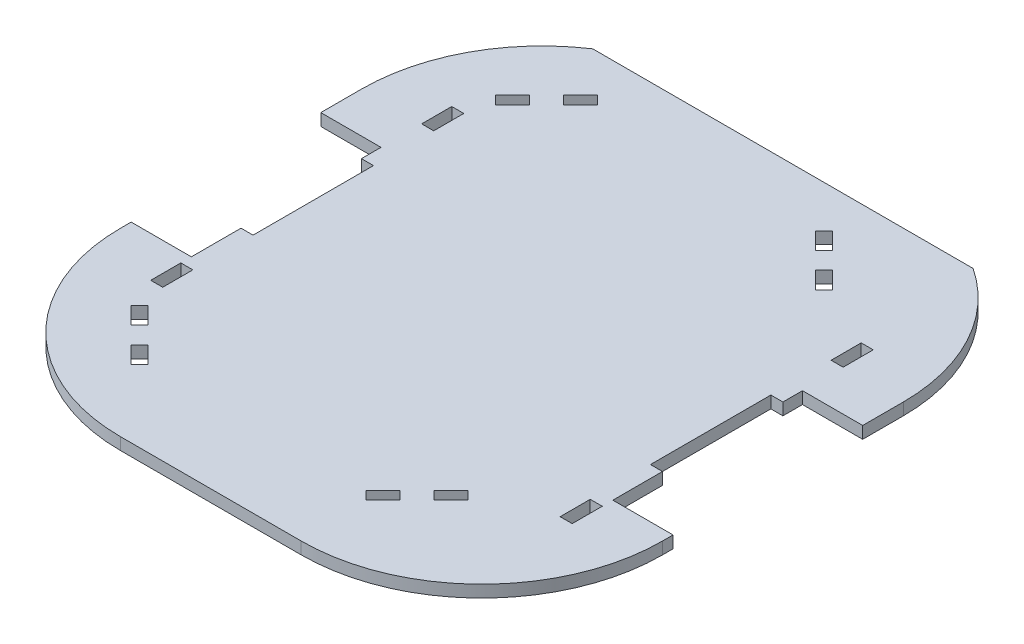
from build123d import *

# Parameters (mm, degrees)
SKETCH1_W            = 228.6
SKETCH1_H            = 241.3
BOSS_EXTRUDE1_DEPTH  = 5.08
CUT_EXTRUDE1_REACH   = 334.43
SKETCH2_W            = 25.4
SKETCH2_H            = 80
CUT_EXTRUDE2_REACH   = 334.43
SKETCH3_W            = 5.08
SKETCH3_H            = 12.7
SKETCH3_H_2          = 50.8
CUT_EXTRUDE3_REACH   = 334.43
CUT_EXTRUDE4_REACH   = 334.43
MIRROR4_COPY_1_REACH = 334.43
MIRROR4_COPY_2_REACH = 334.43


with BuildPart() as part:
    # Sketch1 → Boss-Extrude1 (new body)
    with BuildSketch(Plane(origin=(0, 0, 0), x_dir=(1, 0, 0), z_dir=(0, 1, 0))):
        with Locations((114.3, 120.65)):
            Rectangle(SKETCH1_W, SKETCH1_H)
    extrude(amount=BOSS_EXTRUDE1_DEPTH)

    # Sketch2 → Cut-Extrude1 (cut, up to next)
    with BuildSketch(Plane(origin=(0, 5.08, 0), x_dir=(1, 0, 0), z_dir=(0, 1, 0)), mode=Mode.PRIVATE) as cut_extrude1_sk1:
        with Locations((12.7, 120.65)):
            Rectangle(SKETCH2_W, SKETCH2_H)
    cut_extrude1_tool1 = extrude(cut_extrude1_sk1.sketch, amount=-CUT_EXTRUDE1_REACH, mode=Mode.PRIVATE) & part.part
    cut_extrude1 = cut_extrude1_tool1.solids().sort_by_distance((12.7, 5.08, -120.65))[0]
    add(cut_extrude1, mode=Mode.SUBTRACT)

    # Mirror1: Cut-Extrude1 across plane
    add(cut_extrude1.mirror(Plane.ZY.offset(-114.3)), mode=Mode.SUBTRACT)

    # Sketch3 → Cut-Extrude2 (cut, up to next)
    with BuildSketch(Plane.XZ, mode=Mode.PRIVATE) as cut_extrude2_sk1:
        with Locations((27.94, -184.15)):
            Rectangle(SKETCH3_W, SKETCH3_H)
    cut_extrude2_tool1 = extrude(cut_extrude2_sk1.sketch, amount=-CUT_EXTRUDE2_REACH, mode=Mode.PRIVATE) & part.part
    # Sketch3 → Cut-Extrude2 (cut, up to next)
    with BuildSketch(Plane.XZ, mode=Mode.PRIVATE) as cut_extrude2_sk2:
        with Locations((27.94, -127)):
            Rectangle(SKETCH3_W, SKETCH3_H_2)
    cut_extrude2_tool2 = extrude(cut_extrude2_sk2.sketch, amount=-CUT_EXTRUDE2_REACH, mode=Mode.PRIVATE) & part.part
    # Sketch3 → Cut-Extrude2 (cut, up to next)
    with BuildSketch(Plane.XZ, mode=Mode.PRIVATE) as cut_extrude2_sk3:
        with Locations((27.94, -69.85)):
            Rectangle(SKETCH3_W, SKETCH3_H)
    cut_extrude2_tool3 = extrude(cut_extrude2_sk3.sketch, amount=-CUT_EXTRUDE2_REACH, mode=Mode.PRIVATE) & part.part
    cut_extrude2_1 = cut_extrude2_tool1.solids().sort_by_distance((27.94, 0, -184.15))[0]
    add(cut_extrude2_1, mode=Mode.SUBTRACT)
    cut_extrude2_2 = cut_extrude2_tool2.solids().sort_by_distance((27.94, 0, -127))[0]
    add(cut_extrude2_2, mode=Mode.SUBTRACT)
    cut_extrude2_3 = cut_extrude2_tool3.solids().sort_by_distance((27.94, 0, -69.85))[0]
    add(cut_extrude2_3, mode=Mode.SUBTRACT)
    cut_extrude2 = cut_extrude2_1 + cut_extrude2_2 + cut_extrude2_3  # Cut-Extrude2 as one shape, for the pattern or mirror that repeats it

    # Mirror2: Cut-Extrude2 across plane
    add(cut_extrude2.mirror(Plane.ZY.offset(-114.3)), mode=Mode.SUBTRACT)

    # Sketch4 → Cut-Extrude3 (cut, up to next)
    with BuildSketch(Plane.XZ, mode=Mode.PRIVATE) as cut_extrude3_sk1:
        Polygon((55.639202938, -221.813411753), (48.454998041, -214.629206856), (44.862895593, -218.221309304), (52.047100489, -225.405514201), align=None)
    cut_extrude3_tool1 = extrude(cut_extrude3_sk1.sketch, amount=-CUT_EXTRUDE3_REACH, mode=Mode.PRIVATE) & part.part
    # Sketch4 → Cut-Extrude3 (cut, up to next)
    with BuildSketch(Plane.XZ, mode=Mode.PRIVATE) as cut_extrude3_sk2:
        Polygon((41.270793144, -207.445001959), (34.086588247, -200.260797062), (30.494485799, -203.852899511), (37.678690696, -211.037104407), align=None)
    cut_extrude3_tool2 = extrude(cut_extrude3_sk2.sketch, amount=-CUT_EXTRUDE3_REACH, mode=Mode.PRIVATE) & part.part
    # Sketch4 → Cut-Extrude3 (cut, up to next)
    with BuildSketch(Plane.XZ, mode=Mode.PRIVATE) as cut_extrude3_sk3:
        Polygon((34.086588247, -53.739202938), (41.270793144, -46.554998041), (37.678690696, -42.962895593), (30.494485799, -50.147100489), align=None)
    cut_extrude3_tool3 = extrude(cut_extrude3_sk3.sketch, amount=-CUT_EXTRUDE3_REACH, mode=Mode.PRIVATE) & part.part
    # Sketch4 → Cut-Extrude3 (cut, up to next)
    with BuildSketch(Plane.XZ, mode=Mode.PRIVATE) as cut_extrude3_sk4:
        Polygon((48.454998041, -39.370793144), (55.639202938, -32.186588247), (52.047100489, -28.594485799), (44.862895593, -35.778690696), align=None)
    cut_extrude3_tool4 = extrude(cut_extrude3_sk4.sketch, amount=-CUT_EXTRUDE3_REACH, mode=Mode.PRIVATE) & part.part
    # Sketch4 → Cut-Extrude3 (cut, up to next)
    with BuildSketch(Plane.XZ, mode=Mode.PRIVATE) as cut_extrude3_sk5:
        Polygon((147.560797062, -32.186588247), (154.745001959, -39.370793144), (158.337104407, -35.778690696), (151.152899511, -28.594485799), align=None)
    cut_extrude3_tool5 = extrude(cut_extrude3_sk5.sketch, amount=-CUT_EXTRUDE3_REACH, mode=Mode.PRIVATE) & part.part
    # Sketch4 → Cut-Extrude3 (cut, up to next)
    with BuildSketch(Plane.XZ, mode=Mode.PRIVATE) as cut_extrude3_sk6:
        Polygon((161.929206856, -46.554998041), (169.113411753, -53.739202938), (172.705514201, -50.147100489), (165.521309304, -42.962895593), align=None)
    cut_extrude3_tool6 = extrude(cut_extrude3_sk6.sketch, amount=-CUT_EXTRUDE3_REACH, mode=Mode.PRIVATE) & part.part
    # Sketch4 → Cut-Extrude3 (cut, up to next)
    with BuildSketch(Plane.XZ, mode=Mode.PRIVATE) as cut_extrude3_sk7:
        Polygon((154.745001959, -214.629206856), (147.560797062, -221.813411753), (151.152899511, -225.405514201), (158.337104407, -218.221309304), align=None)
    cut_extrude3_tool7 = extrude(cut_extrude3_sk7.sketch, amount=-CUT_EXTRUDE3_REACH, mode=Mode.PRIVATE) & part.part
    # Sketch4 → Cut-Extrude3 (cut, up to next)
    with BuildSketch(Plane.XZ, mode=Mode.PRIVATE) as cut_extrude3_sk8:
        Polygon((169.113411753, -200.260797062), (161.929206856, -207.445001959), (165.521309304, -211.037104407), (172.705514201, -203.852899511), align=None)
    cut_extrude3_tool8 = extrude(cut_extrude3_sk8.sketch, amount=-CUT_EXTRUDE3_REACH, mode=Mode.PRIVATE) & part.part
    add(cut_extrude3_tool1.solids().sort_by_distance((50.251049, 0, -220.017361))[0], mode=Mode.SUBTRACT)
    add(cut_extrude3_tool2.solids().sort_by_distance((35.882639, 0, -205.648951))[0], mode=Mode.SUBTRACT)
    add(cut_extrude3_tool3.solids().sort_by_distance((35.882639, 0, -48.351049))[0], mode=Mode.SUBTRACT)
    add(cut_extrude3_tool4.solids().sort_by_distance((50.251049, 0, -33.982639))[0], mode=Mode.SUBTRACT)
    add(cut_extrude3_tool5.solids().sort_by_distance((152.948951, 0, -33.982639))[0], mode=Mode.SUBTRACT)
    add(cut_extrude3_tool6.solids().sort_by_distance((167.317361, 0, -48.351049))[0], mode=Mode.SUBTRACT)
    add(cut_extrude3_tool7.solids().sort_by_distance((152.948951, 0, -220.017361))[0], mode=Mode.SUBTRACT)
    add(cut_extrude3_tool8.solids().sort_by_distance((167.317361, 0, -205.648951))[0], mode=Mode.SUBTRACT)

    # Sketch5 → Cut-Extrude4 (cut, up to next)
    with BuildSketch(Plane.XZ, mode=Mode.PRIVATE) as cut_extrude4_sk1:
        with BuildLine():
            Line((0, -76.2), (0, 0))
            Line((0, 0), (76.2, 0))
            ThreePointArc((76.2, 0), (22.318463274, -22.318463274), (0, -76.2))
        make_face()
    cut_extrude4_tool1 = extrude(cut_extrude4_sk1.sketch, amount=-CUT_EXTRUDE4_REACH, mode=Mode.PRIVATE) & part.part
    cut_extrude4 = cut_extrude4_tool1.solids().sort_by_distance((17.020637, 0, -17.020637))[0]
    add(cut_extrude4, mode=Mode.SUBTRACT)

    # Mirror3: Cut-Extrude4 across plane
    add(cut_extrude4.mirror(Plane.ZY.offset(-114.3)), mode=Mode.SUBTRACT)

    # Mirror4 copy 1 sketch → Mirror4 copy 1 (cut, up to next)
    with BuildSketch(Plane(origin=(228.6, 0, -254), x_dir=(-1, 0, 0), z_dir=(0, -1, 0)), mode=Mode.PRIVATE) as mirror4_copy_1_sk1:
        with BuildLine():
            Line((0, -76.2), (0, 0))
            Line((0, 0), (76.2, 0))
            ThreePointArc((76.2, 0), (22.318463274, -22.318463274), (0, -76.2))
        make_face()
    mirror4_copy_1_tool1 = extrude(mirror4_copy_1_sk1.sketch, amount=-MIRROR4_COPY_1_REACH, mode=Mode.PRIVATE) & part.part
    add(mirror4_copy_1_tool1.solids().sort_by_distance((211.579363, 0, -236.979363))[0], mode=Mode.SUBTRACT)

    # Mirror4 copy 2 sketch → Mirror4 copy 2 (cut, up to next)
    with BuildSketch(Plane(origin=(0, 0, -254), x_dir=(1, 0, 0), z_dir=(0, -1, 0)), mode=Mode.PRIVATE) as mirror4_copy_2_sk1:
        with BuildLine():
            Line((0, 76.2), (0, 0))
            Line((0, 0), (76.2, 0))
            ThreePointArc((76.2, 0), (22.318463274, 22.318463274), (0, 76.2))
        make_face()
    mirror4_copy_2_tool1 = extrude(mirror4_copy_2_sk1.sketch, amount=-MIRROR4_COPY_2_REACH, mode=Mode.PRIVATE) & part.part
    add(mirror4_copy_2_tool1.solids().sort_by_distance((17.020637, 0, -236.979363))[0], mode=Mode.SUBTRACT)


solid = part.part
